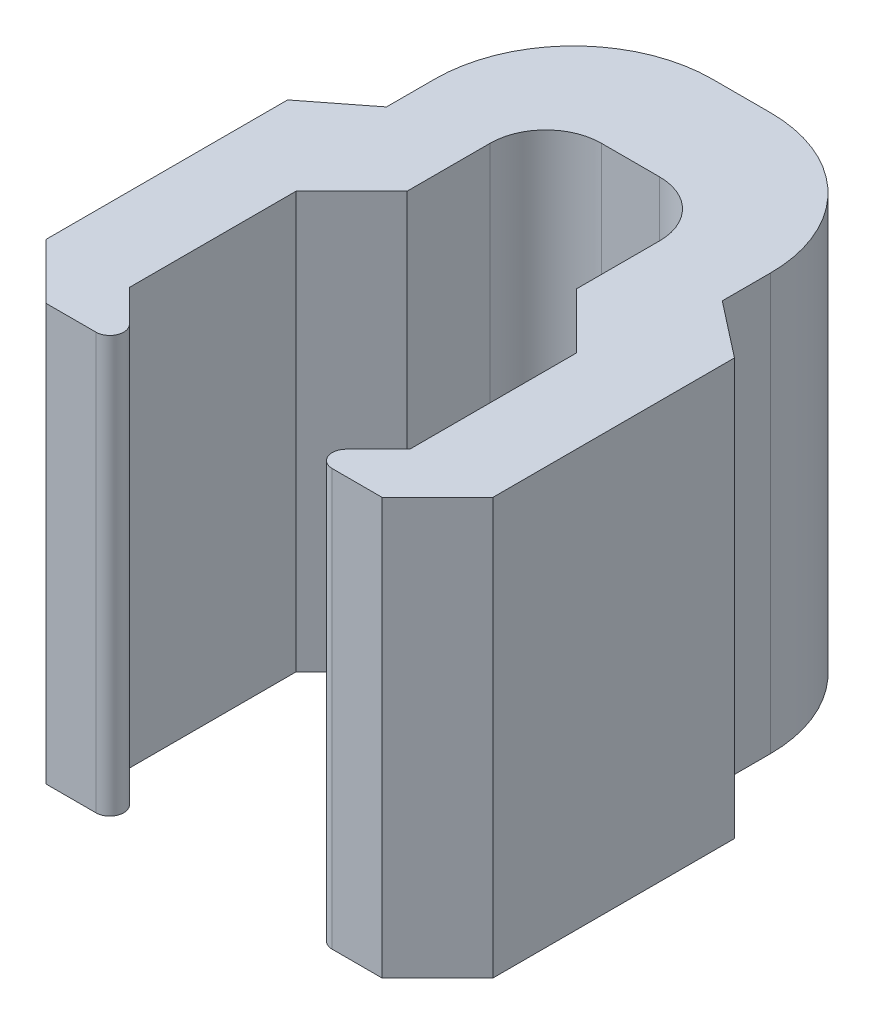
from build123d import *

# Parameters (mm, degrees)
BOSS_EXTRUDE1_DEPTH = 15
CHAMFER1_SIZE       = 2
FILLET1_R           = 2
FILLET3_R           = 5
FILLET4_R           = 0.5


with BuildPart() as part:
    # Sketch2 → Boss-Extrude1 (new body)
    with BuildSketch(Plane(origin=(0, 0, 0), x_dir=(1, 0, 0), z_dir=(0, 1, 0))):
        Polygon((-14.166102689, -0.628958771), (-9.166102689, -0.628958771), (-11.166102689, 1.371041229), (-11.166102689, 7.371041229), (-9.166102689, 9.371041229), (-9.166102689, 14.371041229), (-3.066102689, 14.371041229), (-3.066102689, 9.371041229), (-1.066102689, 7.371041229), (-1.066102689, 1.371041229), (-3.066102689, -0.628958771), (1.933897311, -0.628958771), (1.933897311, 10.071041229), (-0.066102689, 11.631429668), (-0.066102689, 18.371041229), (-12.166102689, 18.371041229), (-12.166102689, 11.631429668), (-14.166102689, 10.071041229), align=None)
    extrude(amount=BOSS_EXTRUDE1_DEPTH)

    # Chamfer1
    chamfer1_edges = [part.edges().sort_by_distance(p)[0] for p in [
        (-14.166102689, 7.5, 0.628958771),
        (1.933897311, 7.5, 0.628958771),
    ]]
    chamfer(chamfer1_edges, length=CHAMFER1_SIZE)

    # Fillet1
    fillet1_edges = [part.edges().sort_by_distance(p)[0] for p in [
        (-3.066102689, 7.5, -14.371041229),
        (-9.166102689, 7.5, -14.371041229),
    ]]
    fillet(fillet1_edges, radius=FILLET1_R)

    # Fillet3
    fillet3_edges = [part.edges().sort_by_distance(p)[0] for p in [
        (-12.166102689, 7.5, -18.371041229),
        (-0.066102689, 7.5, -18.371041229),
    ]]
    fillet(fillet3_edges, radius=FILLET3_R)

    # Fillet4
    fillet4_edges = [part.edges().sort_by_distance(p)[0] for p in [
        (-9.166102689, 7.5, 0.628958771),
        (-3.066102689, 7.5, 0.628958771),
    ]]
    fillet(fillet4_edges, radius=FILLET4_R)


solid = part.part
